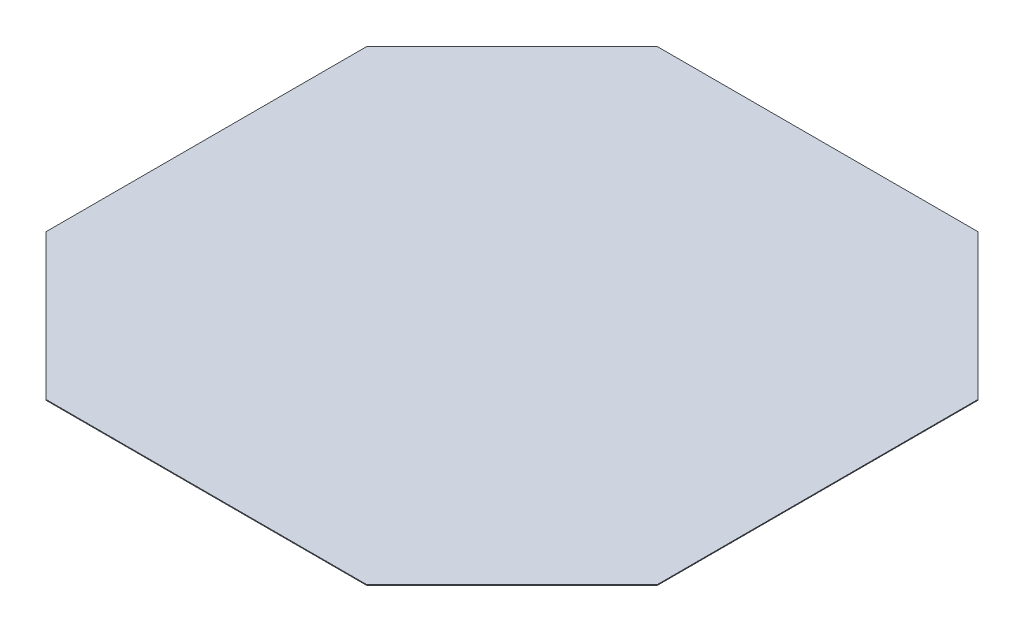
from build123d import *

# Parameters (mm, degrees)
EXTRUDE1_DEPTH = 3.175


with BuildPart() as part:
    # Sketch1 → Extrude1 (new body)
    with BuildSketch(Plane(origin=(0, 0, 0), x_dir=(1, 0, 0), z_dir=(0, 1, 0))):
        Polygon((-673.1, 1282.7), (-1282.7, 673.1), (-1282.7, -673.1), (-673.1, -1282.7), (673.1, -1282.7), (1282.7, -673.1), (1282.7, 673.1), (673.1, 1282.7), align=None)
    extrude(amount=EXTRUDE1_DEPTH)


solid = part.part
